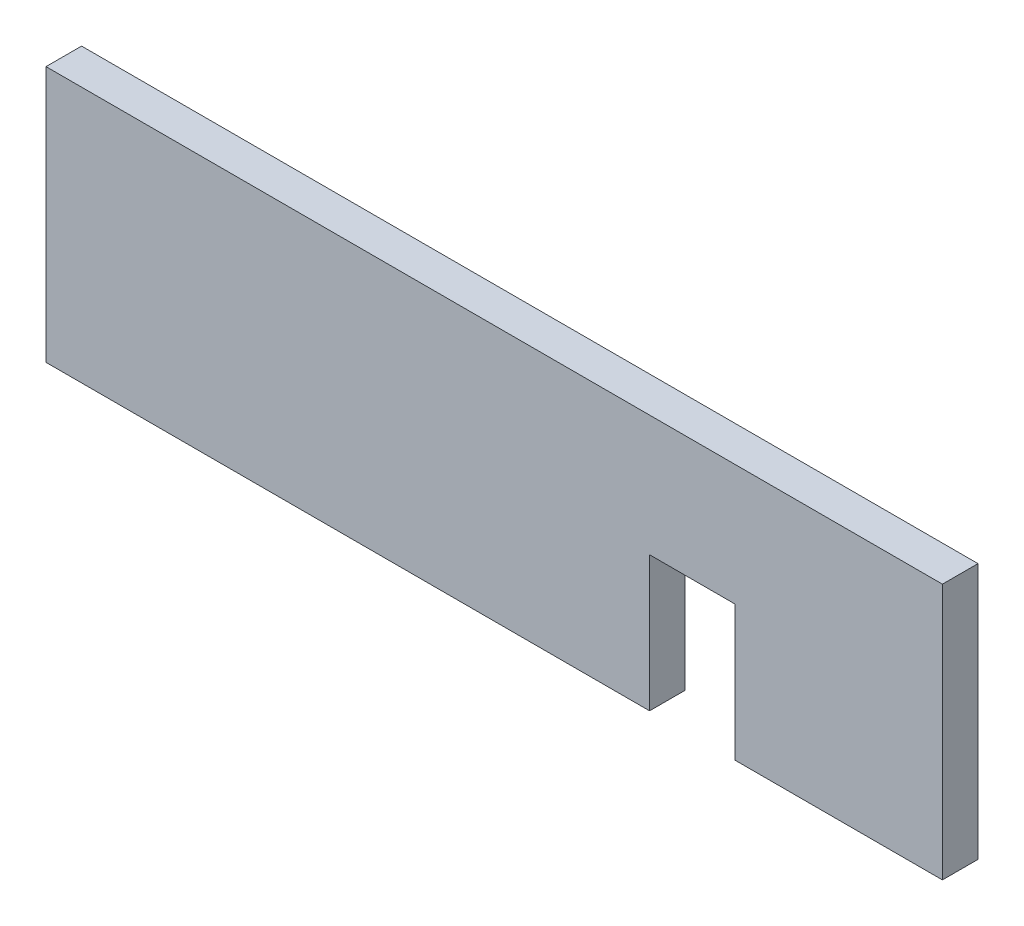
from build123d import *

# Parameters (mm, degrees)
SKETCH1_W           = 40
SKETCH1_H           = 11.43
BOSS_EXTRUDE1_DEPTH = 1.5875
SKETCH2_W           = 3.81
SKETCH2_H           = 6.305748899
CUT_EXTRUDE1_DEPTH  = 2.54


with BuildPart() as part:
    # Sketch1 → Boss-Extrude1 (new body)
    with BuildSketch(Plane.XY):
        with Locations((-44.862738222, 6.327918823)):
            Rectangle(SKETCH1_W, SKETCH1_H)
    extrude(amount=BOSS_EXTRUDE1_DEPTH)

    # Sketch2 → Cut-Extrude1 (cut)
    with BuildSketch(Plane.XY.offset(1.5875)):
        with Locations((-36.025931104, 3.493285759)):
            Rectangle(SKETCH2_W, SKETCH2_H)
    extrude(amount=-CUT_EXTRUDE1_DEPTH, mode=Mode.SUBTRACT)


solid = part.part
